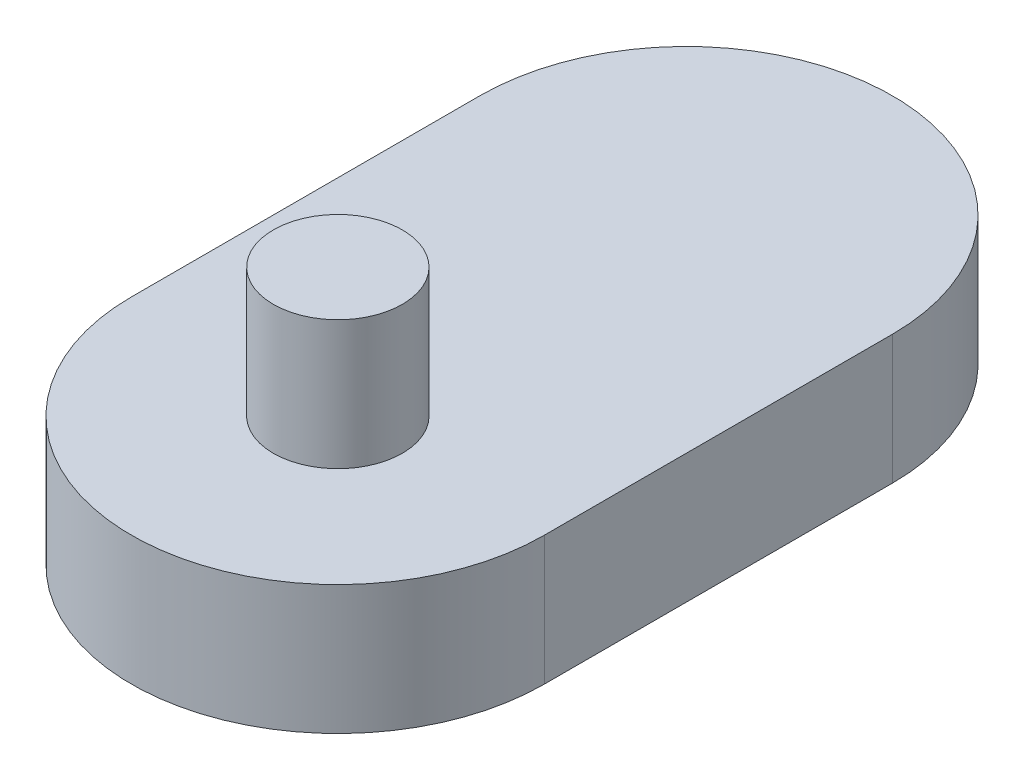
from build123d import *

# Parameters (mm, degrees)
BOSS_EXTRUDE1_DEPTH = 2.5
BOSS_EXTRUDE2_DEPTH = 2.5
SKETCH3_R           = 1.25
BOSS_EXTRUDE3_DEPTH = 2.5
SKETCH4_R           = 1.25
BOSS_EXTRUDE4_DEPTH = 2.5


with BuildPart() as part:
    # Sketch1 → Boss-Extrude1 (new body)
    with BuildSketch(Plane(origin=(0, 0, 0), x_dir=(1, 0, 0), z_dir=(0, 1, 0))):
        with BuildLine():
            Line((4, 6.75), (4, 0))
            ThreePointArc((4, 0), (0, -4), (-4, 0))
            Line((-4, 0), (-4, 6.75))
            ThreePointArc((-4, 6.75), (0, 10.75), (4, 6.75))
        make_face()
    extrude(amount=BOSS_EXTRUDE1_DEPTH)

    # Sketch1_3 → Boss-Extrude2 (add)
    with BuildSketch(Plane(origin=(0, 0, 0), x_dir=(1, 0, 0), z_dir=(0, 1, 0))):
        with BuildLine():
            Line((4, 6.75), (4, 0))
            ThreePointArc((4, 0), (0, -4), (-4, 0))
            Line((-4, 0), (-4, 6.75))
            ThreePointArc((-4, 6.75), (0, 10.75), (4, 6.75))
        make_face()
    extrude(amount=BOSS_EXTRUDE2_DEPTH)

    # Sketch3 → Boss-Extrude3 (add)
    with BuildSketch(Plane(origin=(0, 2.5, 0), x_dir=(1, 0, 0), z_dir=(0, 1, 0))):
        Circle(SKETCH3_R)
    extrude(amount=BOSS_EXTRUDE3_DEPTH)

    # Sketch4 → Boss-Extrude4 (add)
    with BuildSketch(Plane.XZ):
        with Locations((0, -6.75)):
            Circle(SKETCH4_R)
    extrude(amount=BOSS_EXTRUDE4_DEPTH)


solid = part.part
